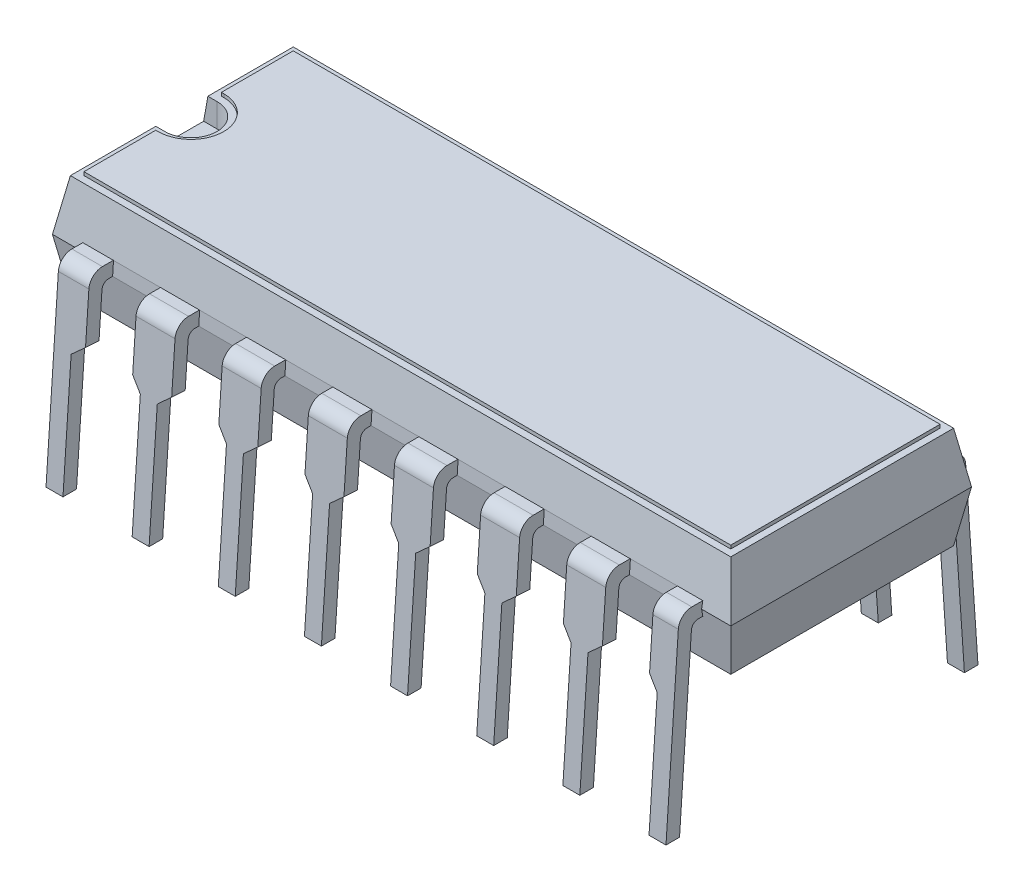
from build123d import *

# Parameters (mm, degrees)
SKETCH1_W                     = 20
SKETCH1_H                     = 7.1
BOSS_EXTRUDE1_DEPTH           = 1.5
BOSS_EXTRUDE1_TAPER           = 10
BOSS_EXTRUDE1_OTHER_WAY_DEPTH = 1.5
BOSS_EXTRUDE1_OTHER_WAY_TAPER = 10
CUT_EXTRUDE1_DEPTH            = 0.7
BOSS_EXTRUDE2_DEPTH           = 9.14
CUT_EXTRUDE2_DEPTH            = 0.7
BOSS_EXTRUDE3_DEPTH           = 0.1


with BuildPart() as part:
    # Sketch1 → Boss-Extrude1 (new body)
    with BuildSketch(Plane(origin=(0, 0, 0), x_dir=(1, 0, 0), z_dir=(0, 1, 0))):
        Rectangle(SKETCH1_W, SKETCH1_H)
    extrude(amount=BOSS_EXTRUDE1_DEPTH, taper=BOSS_EXTRUDE1_TAPER)

    # Sketch1 → Boss-Extrude1 other way (add)
    with BuildSketch(Plane(origin=(0, 0, 0), x_dir=(1, 0, 0), z_dir=(0, 1, 0))):
        Rectangle(SKETCH1_W, SKETCH1_H)
    extrude(amount=-BOSS_EXTRUDE1_OTHER_WAY_DEPTH, taper=BOSS_EXTRUDE1_OTHER_WAY_TAPER)

    # Sketch2 → Cut-Extrude1 (cut)
    with BuildSketch(Plane(origin=(0, 1.5, 0), x_dir=(1, 0, 0), z_dir=(0, 1, 0))):
        with BuildLine():
            Line((-10, 0.767705139), (-10, -0.767705139))
            Line((-10, -0.767705139), (-9.466492762, -0.767705139))
            ThreePointArc((-9.466492762, -0.767705139), (-8.698787623, 0), (-9.466492762, 0.767705139))
            Line((-9.466492762, 0.767705139), (-10, 0.767705139))
        make_face()
    extrude(amount=-CUT_EXTRUDE1_DEPTH, mode=Mode.SUBTRACT)

    # Sketch4 → Boss-Extrude2 (add, symmetric)
    with BuildSketch(Plane(origin=(0, 0, 0), x_dir=(0, 0, -1), z_dir=(1, 0, 0))):
        with BuildLine():
            Line((-2.344371556, 0.2), (-2.344371556, -0.2))
            Line((-2.344371556, -0.2), (-3.650804232, -0.2))
            ThreePointArc((-3.650804232, -0.2), (-3.787316583, -0.253834416), (-3.850338307, -0.386356222))
            Line((-3.850338307, -0.386356222), (-4.2, -5.5))
            Line((-4.2, -5.5), (-4.6, -5.5))
            Line((-4.6, -5.5), (-4.235729733, -0.172712443))
            ThreePointArc((-4.235729733, -0.172712443), (-4.109686285, 0.092331167), (-3.836661582, 0.2))
            Line((-3.836661582, 0.2), (-2.344371556, 0.2))
        make_face()
    boss_extrude2 = extrude(amount=BOSS_EXTRUDE2_DEPTH, both=True)

    # Sketch5 → Cut-Extrude2 (cut)
    with BuildSketch(Plane(origin=(0, 0.287479857, 4.204262618), x_dir=(1, 0, 0), z_dir=(0, 0.068218892, 0.997670378))):
        Polygon((-8.64, -5.800993982), (-8.64, -2.270639387), (-8.24, -1.909960308), (-8.24, -0.040237225), (-6.85, -0.040237225), (-6.85, -1.909960308), (-6.6, -2.270639387), (-6.6, -5.800993982), align=None)
        Polygon((-6.1, -5.800993982), (-6.1, -2.270639387), (-5.7, -1.909960308), (-5.7, -0.040237225), (-4.31, -0.040237225), (-4.31, -1.909960308), (-4.06, -2.270639387), (-4.06, -5.800993982), align=None)
        Polygon((-3.56, -5.800993982), (-3.56, -2.270639387), (-3.16, -1.909960308), (-3.16, -0.040237225), (-1.77, -0.040237225), (-1.77, -1.909960308), (-1.52, -2.270639387), (-1.52, -5.800993982), align=None)
        Polygon((-1.02, -5.800993982), (-1.02, -2.270639387), (-0.62, -1.909960308), (-0.62, -0.040237225), (0.77, -0.040237225), (0.77, -1.909960308), (1.02, -2.270639387), (1.02, -5.800993982), align=None)
        Polygon((1.52, -5.800993982), (1.52, -2.270639387), (1.92, -1.909960308), (1.92, -0.040237225), (3.31, -0.040237225), (3.31, -1.909960308), (3.56, -2.270639387), (3.56, -5.800993982), align=None)
        Polygon((4.06, -5.800993982), (4.06, -2.270639387), (4.46, -1.909960308), (4.46, -0.040237225), (5.85, -0.040237225), (5.85, -1.909960308), (6.1, -2.270639387), (6.1, -5.800993982), align=None)
        Polygon((6.6, -5.800993982), (6.6, -2.270639387), (7, -1.909960308), (7, -0.040237225), (8.39, -0.040237225), (8.39, -1.909960308), (8.64, -2.270639387), (8.64, -5.800993982), align=None)
    cut_extrude2 = extrude(amount=-CUT_EXTRUDE2_DEPTH, mode=Mode.SUBTRACT)

    # Mirror1: Boss-Extrude2, Cut-Extrude2 across plane
    add(boss_extrude2.mirror(Plane.XY))
    add(cut_extrude2.mirror(Plane.XY), mode=Mode.SUBTRACT)

    # Sketch6 → Boss-Extrude3 (add)
    with BuildSketch(Plane(origin=(0, 1.5, 0), x_dir=(1, 0, 0), z_dir=(0, 1, 0))):
        with BuildLine():
            Line((9.535509529, 3.085509529), (-9.535509529, 3.085509529))
            Line((-9.535509529, 3.085509529), (-9.535509529, 0.967705139))
            Line((-9.535509529, 0.967705139), (-9.466492762, 0.967705139))
            ThreePointArc((-9.466492762, 0.967705139), (-8.498787623, 0), (-9.466492762, -0.967705139))
            Line((-9.466492762, -0.967705139), (-9.535509529, -0.967705139))
            Line((-9.535509529, -0.967705139), (-9.535509529, -3.085509529))
            Line((-9.535509529, -3.085509529), (9.535509529, -3.085509529))
            Line((9.535509529, -3.085509529), (9.535509529, 3.085509529))
        make_face()
    extrude(amount=BOSS_EXTRUDE3_DEPTH)


solid = part.part
